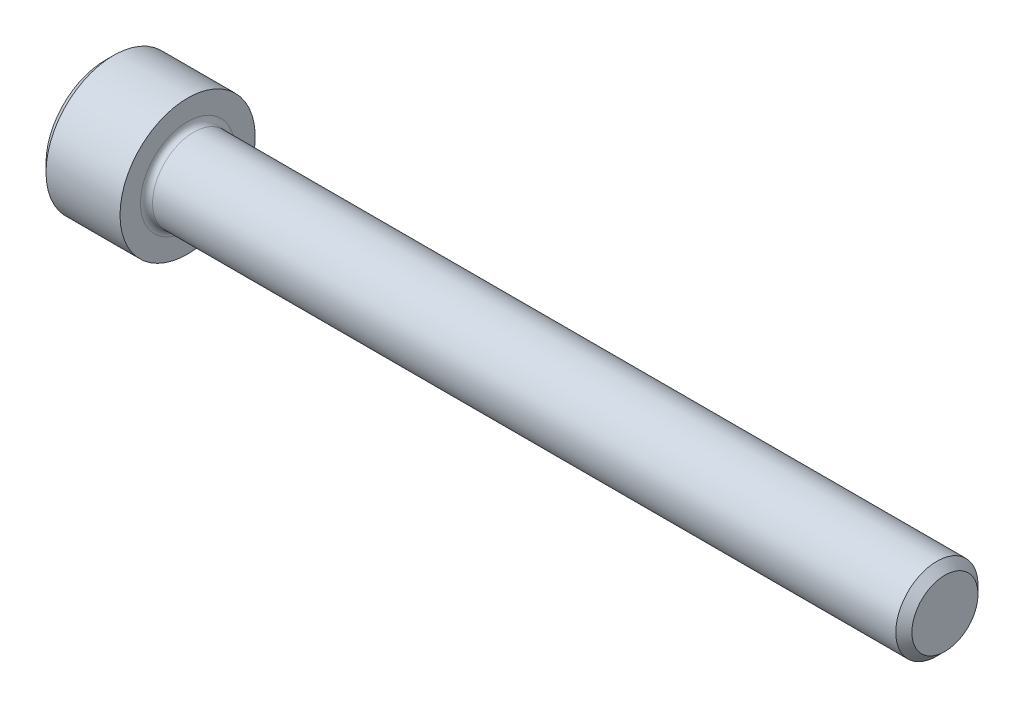
from build123d import *

# Parameters (mm, degrees)
FILLET1_R   = 0.3556
HEX_2_DEPTH = 2.286


with BuildPart() as part:
    # BodySke → Base-Revolve (revolve)
    with BuildSketch(Plane.XY, mode=Mode.PRIVATE) as base_revolve_sk:
        Polygon((0, 0), (0, 3.48615), (0.4826, 3.96875), (4.826, 3.96875), (4.826, 2.413), (48.80356, 2.413), (49.276, 1.94056), (49.276, 0), align=None)
    revolve(base_revolve_sk.sketch.rotate(Axis((-31.75, 0, 0), (1, 0, 0)), 90), axis=Axis((-31.75, 0, 0), (1, 0, 0)))  # turned: the seam where the file's is

    # Fillet1
    fillet1_edges = [part.edges().sort_by_distance(p)[0] for p in [
        (4.826, 0, -2.413),
    ]]
    fillet(fillet1_edges, radius=FILLET1_R)

    # Sketch2 → Hex-PreBroach (revolve, cut)
    with BuildSketch(Plane.XY, mode=Mode.PRIVATE) as hex_prebroach_sk:
        Polygon((0, 1.98501), (2.286, 1.98501), (3.432046058, 0), (0, 0), align=None)
    revolve(hex_prebroach_sk.sketch.rotate(Axis((0, 0, 0), (1, 0, 0)), 90), axis=Axis((0, 0, 0), (1, 0, 0)), mode=Mode.SUBTRACT)  # turned: the seam where the file's is

    # Sketch3 → Hex 2 (cut)
    with BuildSketch(Plane(origin=(0, 0, 0), x_dir=(0, 0.5, 0.866025404), z_dir=(-1, 0, 0))):
        Polygon((1.146046058, 1.98501), (-1.146046058, 1.98501), (-2.292092116, 0), (-1.146046058, -1.98501), (1.146046058, -1.98501), (2.292092116, 0), align=None)
    extrude(amount=-HEX_2_DEPTH, mode=Mode.SUBTRACT)


solid = part.part
